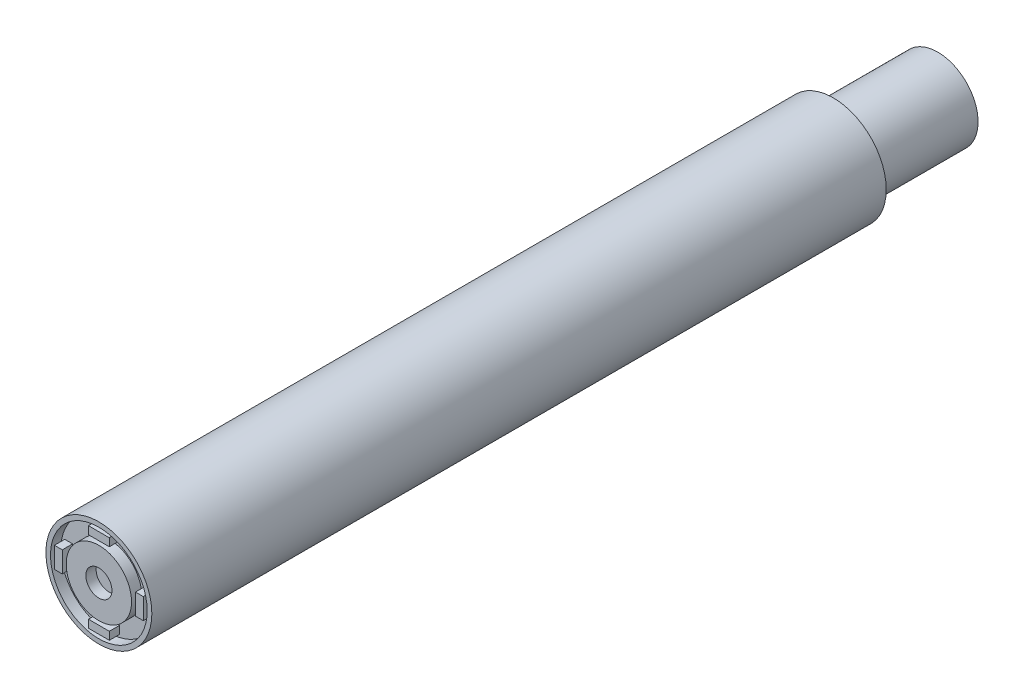
from build123d import *

# Parameters (mm, degrees)
SKETCH1_R           = 2.575
BOSS_EXTRUDE1_DEPTH = 35.7
SKETCH2_R           = 2.35
CUT_EXTRUDE1_DEPTH  = 0.5
SKETCH5_R           = 1.5875
SKETCH5_R_2         = 0.635
BOSS_EXTRUDE2_DEPTH = 0.508
SKETCH6_W           = 1.016
SKETCH6_H           = 0.381
SKETCH6_W_2         = 0.381
SKETCH6_H_2         = 1.016
BOSS_EXTRUDE3_DEPTH = 0.508
SKETCH7_R           = 1.9588
BOSS_EXTRUDE4_DEPTH = 5.08


with BuildPart() as part:
    # Sketch1 → Boss-Extrude1 (new body)
    with BuildSketch(Plane.XY):
        Circle(SKETCH1_R)
    extrude(amount=-BOSS_EXTRUDE1_DEPTH)

    # Sketch2 → Cut-Extrude1 (cut)
    with BuildSketch(Plane.XY):
        Circle(SKETCH2_R)
    extrude(amount=-CUT_EXTRUDE1_DEPTH, mode=Mode.SUBTRACT)

    # Sketch5 → Boss-Extrude2 (add)
    with BuildSketch(Plane.XY):
        Circle(SKETCH5_R)
        Circle(SKETCH5_R_2, mode=Mode.SUBTRACT)
    extrude(amount=-BOSS_EXTRUDE2_DEPTH)

    # Sketch6 → Boss-Extrude3 (add)
    with BuildSketch(Plane.XY):
        with Locations((0, 1.9685)):
            Rectangle(SKETCH6_W, SKETCH6_H)
        with Locations((0, -1.9685)):
            Rectangle(SKETCH6_W, SKETCH6_H)
        with Locations((-1.9685, 0)):
            Rectangle(SKETCH6_W_2, SKETCH6_H_2)
        with Locations((1.9685, 0)):
            Rectangle(SKETCH6_W_2, SKETCH6_H_2)
    extrude(amount=-BOSS_EXTRUDE3_DEPTH)

    # Sketch7 → Boss-Extrude4 (add)
    with BuildSketch(Plane(origin=(0, 0, -35.7), x_dir=(-1, 0, 0), z_dir=(0, 0, -1))):
        Circle(SKETCH7_R)
    extrude(amount=BOSS_EXTRUDE4_DEPTH)


solid = part.part
